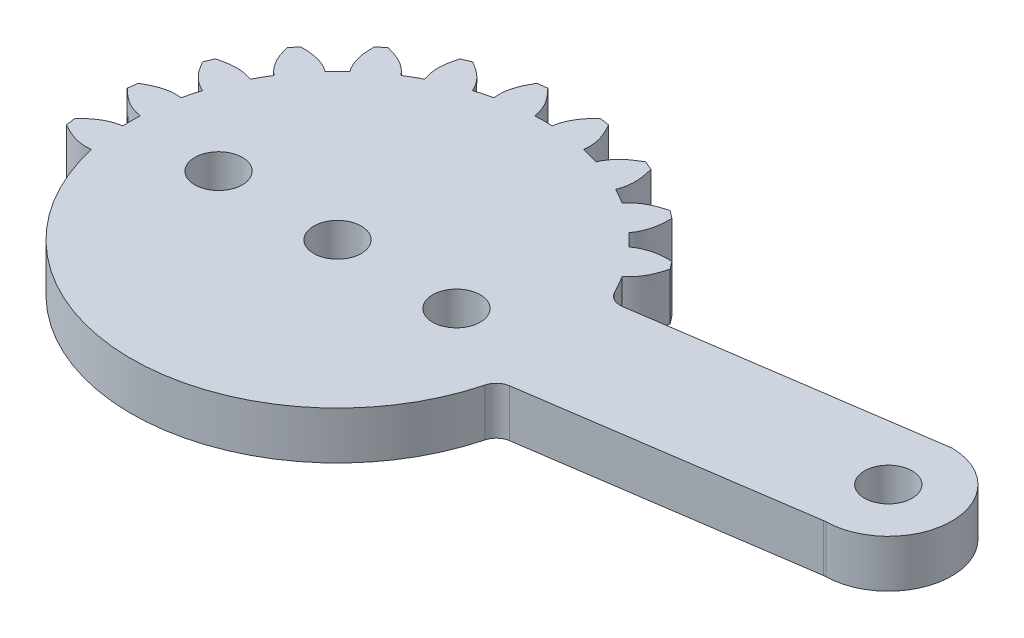
from build123d import *

# Parameters (mm, degrees)
SKETCH1_R           = 1.5
BOSS_EXTRUDE1_DEPTH = 3
SCALE1_SCALE        = 1.8


with BuildPart() as part:
    # Sketch1 → Boss-Extrude1 (new body)
    with BuildSketch(Plane(origin=(0, 0, 0), x_dir=(1, 0, 0), z_dir=(0, 1, 0))):
        with BuildLine():
            Line((12.632699085, 5.340493617), (30.652467528, 7.988606141))
            ThreePointArc((30.652467528, 7.988606141), (30.736256439, 7.997332941), (30.820482547, 7.998976483))
            ThreePointArc((30.820482547, 7.998976483), (34.729974115, 3.985609874), (30.791707503, 0.000476005))
            ThreePointArc((30.791707503, 0.000476005), (30.726552312, -0.002657016), (30.661739998, -0.010031215))
            Line((30.661739998, -0.010031215), (13.400696346, -2.546644602))
            ThreePointArc((13.400696346, -2.546644602), (12.878710947, -2.791300832), (12.578512819, -3.283445639))
            ThreePointArc((12.578512819, -3.283445639), (0.316986254, -12.996134799), (-12.403478945, -3.892776652))
            add(Edge.make_bspline(
                [(-12.403478945, -3.892776652), (-12.568432388, -3.367671042), (-12.688169827, -2.830255546)],
                knots=[0, 0, 0, 0.029411494, 0.029411494, 0.029411494], degree=2))
            add(Edge.make_bspline(
                [(-12.688169827, -2.830255546), (-13.526378309, -2.92825021), (-14.200348489, -2.631756771), (-14.828036033, -2.264806262)],
                knots=[0, 0, 0, 0, 0.585569533, 0.585569533, 0.585569533, 0.585569533], degree=3))
            add(Edge.make_bspline(
                [(-14.828036033, -2.264806262), (-14.874848849, -1.958311002), (-14.908957951, -1.650143267)],
                knots=[0, 0, 0, 1, 1, 1], degree=2))
            add(Edge.make_bspline(
                [(-12.988354961, -0.550123072), (-13.823365068, -0.672411814), (-14.397632122, -1.133238803), (-14.908957951, -1.650143267)],
                knots=[0, 0, 0, 0, 0.585569533, 0.585569533, 0.585569533, 0.585569533], degree=3))
            add(Edge.make_bspline(
                [(-12.988354961, -0.550123072), (-13.003945727, -0.183508375), (-13.00394681, 0.183466584), (-12.988354961, 0.550123072)],
                knots=[0.090903106, 0.090903106, 0.090903106, 0.090903106, 0.120321184, 0.120321184, 0.120321184, 0.120321184], degree=3))
            add(Edge.make_bspline(
                [(-12.988354961, 0.550123072), (-13.823365068, 0.672411814), (-14.397632122, 1.133238803), (-14.908957951, 1.650143267)],
                knots=[0, 0, 0, 0, 0.585569533, 0.585569533, 0.585569533, 0.585569533], degree=3))
            add(Edge.make_bspline(
                [(-14.908957951, 1.650143267), (-14.874848849, 1.958311002), (-14.828036033, 2.264806262)],
                knots=[0, 0, 0, 1, 1, 1], degree=2))
            add(Edge.make_bspline(
                [(-12.688169827, 2.830255546), (-13.526378309, 2.92825021), (-14.200348489, 2.631756771), (-14.828036033, 2.264806262)],
                knots=[0, 0, 0, 0, 0.585569533, 0.585569533, 0.585569533, 0.585569533], degree=3))
            add(Edge.make_bspline(
                [(-12.688169827, 2.830255546), (-12.60833596, 3.18844173), (-12.513361148, 3.542894104), (-12.40340517, 3.893011712)],
                knots=[0.181812796, 0.181812796, 0.181812796, 0.181812796, 0.211230873, 0.211230873, 0.211230873, 0.211230873], degree=3))
            add(Edge.make_bspline(
                [(-12.40340517, 3.893011712), (-13.178312342, 4.227250084), (-13.613740919, 4.821006025), (-13.973859024, 5.452638259)],
                knots=[0, 0, 0, 0, 0.585569533, 0.585569533, 0.585569533, 0.585569533], degree=3))
            add(Edge.make_bspline(
                [(-13.973859024, 5.452638259), (-13.861152482, 5.741477348), (-13.736607963, 6.025412987)],
                knots=[0, 0, 0, 1, 1, 1], degree=2))
            add(Edge.make_bspline(
                [(-11.523306886, 6.017756925), (-12.307591221, 6.329356822), (-13.035334574, 6.217402469), (-13.736607963, 6.025412987)],
                knots=[0, 0, 0, 0, 0.585569533, 0.585569533, 0.585569533, 0.585569533], degree=3))
            add(Edge.make_bspline(
                [(-11.523306886, 6.017756925), (-11.35348747, 6.343077502), (-11.170010092, 6.660869731), (-10.973183814, 6.970598036)],
                knots=[0.272722485, 0.272722485, 0.272722485, 0.272722485, 0.302140562, 0.302140562, 0.302140562, 0.302140562], degree=3))
            add(Edge.make_bspline(
                [(-10.973183814, 6.970598036), (-11.635179408, 7.494008246), (-11.902095771, 8.180229653), (-12.086464697, 8.883544965)],
                knots=[0, 0, 0, 0, 0.585569533, 0.585569533, 0.585569533, 0.585569533], degree=3))
            add(Edge.make_bspline(
                [(-12.086464697, 8.883544965), (-11.90284148, 9.133371501), (-11.709052762, 9.375397774)],
                knots=[0, 0, 0, 1, 1, 1], degree=2))
            add(Edge.make_bspline(
                [(-9.573149625, 8.795158115), (-10.250062131, 9.299128225), (-10.981984149, 9.379342464), (-11.709052762, 9.375397774)],
                knots=[0, 0, 0, 0, 0.585569533, 0.585569533, 0.585569533, 0.585569533], degree=3))
            add(Edge.make_bspline(
                [(-9.573149625, 8.795158115), (-9.324917477, 9.065441278), (-9.065441275, 9.324917485), (-8.795158115, 9.573149625)],
                knots=[0.363632174, 0.363632174, 0.363632174, 0.363632174, 0.393050251, 0.393050251, 0.393050251, 0.393050251], degree=3))
            add(Edge.make_bspline(
                [(-8.795158115, 9.573149625), (-9.299128225, 10.250062131), (-9.379342464, 10.981984149), (-9.375397774, 11.709052762)],
                knots=[0, 0, 0, 0, 0.585569533, 0.585569533, 0.585569533, 0.585569533], degree=3))
            add(Edge.make_bspline(
                [(-9.375397774, 11.709052762), (-9.133371501, 11.90284148), (-8.883544965, 12.086464697)],
                knots=[0, 0, 0, 1, 1, 1], degree=2))
            add(Edge.make_bspline(
                [(-6.970598036, 10.973183814), (-7.494008246, 11.635179408), (-8.180229653, 11.902095771), (-8.883544965, 12.086464697)],
                knots=[0, 0, 0, 0, 0.585569533, 0.585569533, 0.585569533, 0.585569533], degree=3))
            add(Edge.make_bspline(
                [(-6.970598036, 10.973183814), (-6.660869762, 11.170010102), (-6.343077615, 11.353487483), (-6.017756925, 11.523306886)],
                knots=[0.454541863, 0.454541863, 0.454541863, 0.454541863, 0.48395994, 0.48395994, 0.48395994, 0.48395994], degree=3))
            add(Edge.make_bspline(
                [(-6.017756925, 11.523306886), (-6.329356822, 12.307591221), (-6.217402469, 13.035334574), (-6.025412987, 13.736607963)],
                knots=[0, 0, 0, 0, 0.585569533, 0.585569533, 0.585569533, 0.585569533], degree=3))
            add(Edge.make_bspline(
                [(-6.025412987, 13.736607963), (-5.741477348, 13.861152482), (-5.452638259, 13.973859024)],
                knots=[0, 0, 0, 1, 1, 1], degree=2))
            add(Edge.make_bspline(
                [(-3.893011712, 12.40340517), (-4.227250084, 13.178312342), (-4.821006025, 13.613740919), (-5.452638259, 13.973859024)],
                knots=[0, 0, 0, 0, 0.585569533, 0.585569533, 0.585569533, 0.585569533], degree=3))
            add(Edge.make_bspline(
                [(-3.893011712, 12.40340517), (-3.54289478, 12.513361188), (-3.188443695, 12.608336067), (-2.830255546, 12.688169827)],
                knots=[0.545451553, 0.545451553, 0.545451553, 0.545451553, 0.57486963, 0.57486963, 0.57486963, 0.57486963], degree=3))
            add(Edge.make_bspline(
                [(-2.830255546, 12.688169827), (-2.92825021, 13.526378309), (-2.631756771, 14.200348489), (-2.264806262, 14.828036033)],
                knots=[0, 0, 0, 0, 0.585569533, 0.585569533, 0.585569533, 0.585569533], degree=3))
            add(Edge.make_bspline(
                [(-2.264806262, 14.828036033), (-1.958311002, 14.874848849), (-1.650143267, 14.908957951)],
                knots=[0, 0, 0, 1, 1, 1], degree=2))
            add(Edge.make_bspline(
                [(-0.550123072, 12.988354961), (-0.672411814, 13.823365068), (-1.133238803, 14.397632122), (-1.650143267, 14.908957951)],
                knots=[0, 0, 0, 0, 0.585569533, 0.585569533, 0.585569533, 0.585569533], degree=3))
            add(Edge.make_bspline(
                [(-0.550123072, 12.988354961), (-0.183477364, 13.003947374), (0.183477419, 13.003947344), (0.550123072, 12.988354961)],
                knots=[0.636361242, 0.636361242, 0.636361242, 0.636361242, 0.665779319, 0.665779319, 0.665779319, 0.665779319], degree=3))
            add(Edge.make_bspline(
                [(0.550123072, 12.988354961), (0.672411814, 13.823365068), (1.133238803, 14.397632122), (1.650143267, 14.908957951)],
                knots=[0, 0, 0, 0, 0.585569533, 0.585569533, 0.585569533, 0.585569533], degree=3))
            add(Edge.make_bspline(
                [(1.650143267, 14.908957951), (1.958311002, 14.874848849), (2.264806262, 14.828036033)],
                knots=[0, 0, 0, 1, 1, 1], degree=2))
            add(Edge.make_bspline(
                [(2.830255546, 12.688169827), (2.92825021, 13.526378309), (2.631756771, 14.200348489), (2.264806262, 14.828036033)],
                knots=[0, 0, 0, 0, 0.585569533, 0.585569533, 0.585569533, 0.585569533], degree=3))
            add(Edge.make_bspline(
                [(2.830255546, 12.688169827), (3.188443874, 12.608335818), (3.542895259, 12.513360471), (3.893011712, 12.40340517)],
                knots=[0.727270931, 0.727270931, 0.727270931, 0.727270931, 0.756689008, 0.756689008, 0.756689008, 0.756689008], degree=3))
            add(Edge.make_bspline(
                [(3.893011712, 12.40340517), (4.227250084, 13.178312342), (4.821006025, 13.613740919), (5.452638259, 13.973859024)],
                knots=[0, 0, 0, 0, 0.585569533, 0.585569533, 0.585569533, 0.585569533], degree=3))
            add(Edge.make_bspline(
                [(5.452638259, 13.973859024), (5.741477348, 13.861152482), (6.025412987, 13.736607963)],
                knots=[0, 0, 0, 1, 1, 1], degree=2))
            add(Edge.make_bspline(
                [(6.017756925, 11.523306886), (6.329356822, 12.307591221), (6.217402469, 13.035334574), (6.025412987, 13.736607963)],
                knots=[0, 0, 0, 0, 0.585569533, 0.585569533, 0.585569533, 0.585569533], degree=3))
            add(Edge.make_bspline(
                [(6.017756925, 11.523306886), (6.343080162, 11.353483585), (6.660877044, 11.16999893), (6.970598036, 10.973183814)],
                knots=[0.81818062, 0.81818062, 0.81818062, 0.81818062, 0.847598697, 0.847598697, 0.847598697, 0.847598697], degree=3))
            add(Edge.make_bspline(
                [(6.970598036, 10.973183814), (7.494008246, 11.635179408), (8.180229653, 11.902095771), (8.883544965, 12.086464697)],
                knots=[0, 0, 0, 0, 0.585569533, 0.585569533, 0.585569533, 0.585569533], degree=3))
            add(Edge.make_bspline(
                [(8.883544965, 12.086464697), (9.133371501, 11.90284148), (9.375397774, 11.709052762)],
                knots=[0, 0, 0, 1, 1, 1], degree=2))
            add(Edge.make_bspline(
                [(8.795158115, 9.573149625), (9.299128225, 10.250062131), (9.379342464, 10.981984149), (9.375397774, 11.709052762)],
                knots=[0, 0, 0, 0, 0.585569533, 0.585569533, 0.585569533, 0.585569533], degree=3))
            add(Edge.make_bspline(
                [(8.795158115, 9.573149625), (9.065480928, 9.3248566), (9.325031193, 9.065266643), (9.573149625, 8.795158115)],
                knots=[0.909090309, 0.909090309, 0.909090309, 0.909090309, 0.938508386, 0.938508386, 0.938508386, 0.938508386], degree=3))
            add(Edge.make_bspline(
                [(9.573149625, 8.795158115), (10.250062131, 9.299128225), (10.981984149, 9.379342464), (11.709052762, 9.375397774)],
                knots=[0, 0, 0, 0, 0.585569533, 0.585569533, 0.585569533, 0.585569533], degree=3))
            add(Edge.make_bspline(
                [(11.709052762, 9.375397774), (11.90284148, 9.133371501), (12.086464697, 8.883544965)],
                knots=[0, 0, 0, 1, 1, 1], degree=2))
            add(Edge.make_bspline(
                [(10.973183814, 6.970598036), (11.635179408, 7.494008246), (11.902095771, 8.180229653), (12.086464697, 8.883544965)],
                knots=[0, 0, 0, 0, 0.585569533, 0.585569533, 0.585569533, 0.585569533], degree=3))
            ThreePointArc((10.973183814, 6.970598036), (11.297491618, 6.431693645), (11.595354368, 5.87773401))
            ThreePointArc((11.595354368, 5.87773401), (12.027420742, 5.441888374), (12.632699085, 5.340493617))
        make_face()
        Circle(SKETCH1_R, mode=Mode.SUBTRACT)
        with Locations((7.5, 0)):
            Circle(SKETCH1_R, mode=Mode.SUBTRACT)
        with Locations((-7.5, 0)):
            Circle(SKETCH1_R, mode=Mode.SUBTRACT)
        with Locations((30.73, 4)):
            Circle(SKETCH1_R, mode=Mode.SUBTRACT)
    extrude(amount=BOSS_EXTRUDE1_DEPTH)


with BuildPart() as part_1:
    # Scale1: scaled about (5.054854576, 1.5, -1.125448484)
    add(part.part.scale(SCALE1_SCALE).moved(Location((-4.043883661, -1.2, 0.900358787))))


solid = part_1.part
